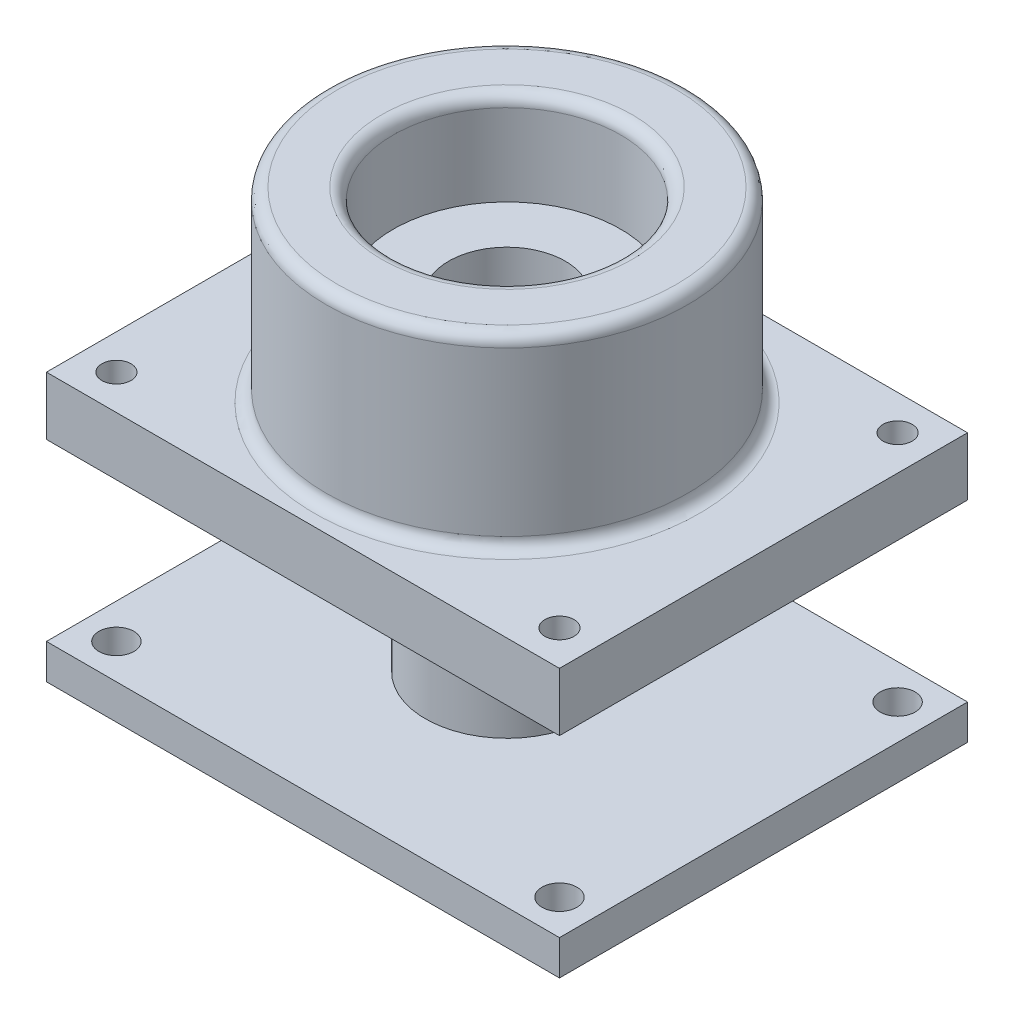
from build123d import *

# Parameters (mm, degrees)
SKETCH1_R           = 15.5
BOSS_EXTRUDE1_DEPTH = 16
SKETCH16_W          = 44
SKETCH16_H          = 35
SKETCH16_R          = 1.25
BOSS_EXTRUDE6_DEPTH = 5
SKETCH17_R          = 9.75
CUT_EXTRUDE5_DEPTH  = 6
SKETCH18_R          = 5
CUT_EXTRUDE7_DEPTH  = 19
FILLET4_R           = 1
FILLET1_R           = 1
FILLET3_R           = 1
SKETCH2_R           = 7
BOSS_EXTRUDE3_DEPTH = 20
SKETCH5_R           = 9.75
CUT_EXTRUDE1_DEPTH  = 8
SKETCH6_R           = 5
CUT_EXTRUDE2_DEPTH  = 30
SKETCH12_W          = 44
SKETCH12_H          = 35
BOSS_EXTRUDE4_DEPTH = 3
SKETCH14_R          = 1.5
CUT_EXTRUDE3_DEPTH  = 3
SKETCH15_R          = 5
CUT_EXTRUDE4_DEPTH  = 3


with BuildPart() as part:
    # Sketch1 → Boss-Extrude1 (new body)
    with BuildSketch(Plane(origin=(0, 0, 0), x_dir=(1, 0, 0), z_dir=(0, 1, 0))):
        with Locations(Location((0, 0, 0), (0, 0, 270))):
            Circle(SKETCH1_R)
    extrude(amount=BOSS_EXTRUDE1_DEPTH)

    # Sketch16 → Boss-Extrude6 (add)
    with BuildSketch(Plane.XZ):
        Rectangle(SKETCH16_W, SKETCH16_H)
        with Locations(Location((-19, 14.5, 0), (0, 0, 270))):
            Circle(SKETCH16_R, mode=Mode.SUBTRACT)
        with Locations(Location((19, 14.5, 0), (0, 0, 270))):
            Circle(SKETCH16_R, mode=Mode.SUBTRACT)
        with Locations(Location((19, -14.5, 0), (0, 0, 270))):
            Circle(SKETCH16_R, mode=Mode.SUBTRACT)
        with Locations(Location((-19, -14.5, 0), (0, 0, 270))):
            Circle(SKETCH16_R, mode=Mode.SUBTRACT)
    extrude(amount=BOSS_EXTRUDE6_DEPTH)

    # Sketch17 → Cut-Extrude5 (cut)
    with BuildSketch(Plane(origin=(0, 16, 0), x_dir=(1, 0, 0), z_dir=(0, 1, 0))):
        with Locations(Location((0, 0, 0), (0, 0, 270))):
            Circle(SKETCH17_R)
    extrude(amount=-CUT_EXTRUDE5_DEPTH, mode=Mode.SUBTRACT)

    # Sketch18 → Cut-Extrude7 (cut)
    with BuildSketch(Plane(origin=(0, 10, 0), x_dir=(1, 0, 0), z_dir=(0, 1, 0))):
        with Locations(Location((0, 0, 0), (0, 0, 270))):
            Circle(SKETCH18_R)
    extrude(amount=-CUT_EXTRUDE7_DEPTH, mode=Mode.SUBTRACT)

    # Fillet4
    fillet4_edges = [part.edges().sort_by_distance(p)[0] for p in [
        (0, 0, -15.5),
    ]]
    fillet(fillet4_edges, radius=FILLET4_R)

    # Fillet1
    fillet1_edges = [part.edges().sort_by_distance(p)[0] for p in [
        (0, 16, -9.75),
    ]]
    fillet(fillet1_edges, radius=FILLET1_R)

    # Fillet3
    fillet3_edges = [part.edges().sort_by_distance(p)[0] for p in [
        (0, 16, -15.5),
    ]]
    fillet(fillet3_edges, radius=FILLET3_R)

    # Sketch2 → Boss-Extrude3 (add)
    with BuildSketch(Plane(origin=(0, 0, 0), x_dir=(-1, 0, 0), z_dir=(0, -1, 0))):
        with Locations(Location((0, 0, 0), (0, 0, 90))):
            Circle(SKETCH2_R)
    extrude(amount=BOSS_EXTRUDE3_DEPTH)

    # Sketch5 → Cut-Extrude1 (cut)
    with BuildSketch(Plane(origin=(0, 16, 0), x_dir=(1, 0, 0), z_dir=(0, 1, 0))):
        with Locations(Location((0, 0, 0), (0, 0, 270))):
            Circle(SKETCH5_R)
    extrude(amount=-CUT_EXTRUDE1_DEPTH, mode=Mode.SUBTRACT)

    # Sketch6 → Cut-Extrude2 (cut)
    with BuildSketch(Plane(origin=(0, 8, 0), x_dir=(1, 0, 0), z_dir=(0, 1, 0))):
        with Locations(Location((0, 0, 0), (0, 0, 270))):
            Circle(SKETCH6_R)
    extrude(amount=-CUT_EXTRUDE2_DEPTH, mode=Mode.SUBTRACT)

    # Sketch12 → Boss-Extrude4 (add)
    with BuildSketch(Plane(origin=(0, -20, 0), x_dir=(-1, 0, 0), z_dir=(0, -1, 0))):
        Rectangle(SKETCH12_W, SKETCH12_H)
    extrude(amount=BOSS_EXTRUDE4_DEPTH)

    # Sketch14 → Cut-Extrude3 (cut)
    with BuildSketch(Plane(origin=(0, -20, 0), x_dir=(-1, 0, 0), z_dir=(0, -1, 0))):
        with Locations(Location((-19, -14.5, 0), (0, 0, 90))):
            Circle(SKETCH14_R)
        with Locations(Location((19, -14.5, 0), (0, 0, 90))):
            Circle(SKETCH14_R)
        with Locations(Location((19, 14.5, 0), (0, 0, 90))):
            Circle(SKETCH14_R)
        with Locations(Location((-19, 14.5, 0), (0, 0, 90))):
            Circle(SKETCH14_R)
    extrude(amount=CUT_EXTRUDE3_DEPTH, mode=Mode.SUBTRACT)

    # Sketch15 → Cut-Extrude4 (cut)
    with BuildSketch(Plane(origin=(0, -20, 0), x_dir=(-1, 0, 0), z_dir=(0, -1, 0))):
        with Locations(Location((0, 0, 0), (0, 0, 270))):
            Circle(SKETCH15_R)
    extrude(amount=CUT_EXTRUDE4_DEPTH, mode=Mode.SUBTRACT)


solid = part.part
